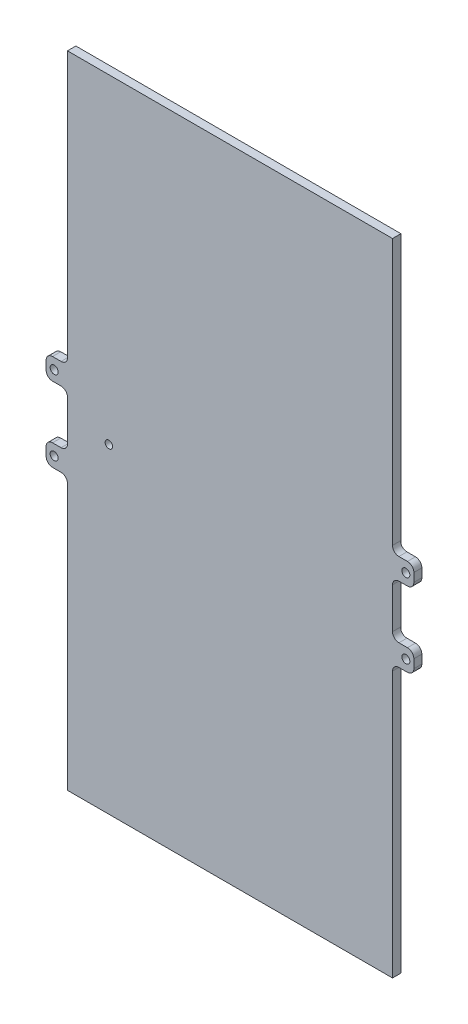
from build123d import *

# Parameters (mm, degrees)
SKETCH1_W               = 120
SKETCH1_H               = 60.9
BOSS_EXTRUDE1_DEPTH     = 1.61
CUT_EXTRUDE1_DEPTH      = 0.5
SKETCH3_W               = 4
SKETCH3_H               = 1.54
BOSS_EXTRUDE2_DEPTH     = 4
SKETCH5_W               = 4
SKETCH5_H               = 1.47
BOSS_EXTRUDE3_DEPTH     = 4
SKETCH7_R               = 0.75
CUT_EXTRUDE3_DEPTH      = 1.07
CUT_EXTRUDE3_DEPTH_BACK = 2.54
FILLET1_R               = 1.2
FILLET2_R               = 1.2
SKETCH8_R               = 0.7
CUT_EXTRUDE4_DEPTH      = 2.61
SKETCH13_W              = 60.9
SKETCH13_H              = 120
CUT_EXTRUDE5_DEPTH      = 0.04
SKETCH14_R              = 0.75
BOSS_EXTRUDE4_DEPTH     = 0.03
SKETCH15_R              = 0.75
CUT_EXTRUDE6_DEPTH      = 0.005


with BuildPart() as part:
    # Sketch1 → Boss-Extrude1 (new body)
    with BuildSketch(Plane(origin=(0, 0, 0), x_dir=(0, 1, 0), z_dir=(0, 0, 1))):
        Rectangle(SKETCH1_W, SKETCH1_H)
    extrude(amount=BOSS_EXTRUDE1_DEPTH)

    # Sketch2 → Cut-Extrude1 (cut)
    with BuildSketch(Plane(origin=(0, 0, 0), x_dir=(1, 0, 0), z_dir=(0, 0, -1))):
        Polygon((28.481704711, 0), (17.415141609, 6.389283186), (17.415141609, -6.389283186), align=None)
    extrude(amount=-CUT_EXTRUDE1_DEPTH, mode=Mode.SUBTRACT)

    # Sketch3 → Boss-Extrude2 (add)
    with BuildSketch(Plane(origin=(-30.45, 0, 0), x_dir=(0, -1, 0), z_dir=(-1, 0, 0))):
        with Locations((-7, 0.805)):
            Rectangle(SKETCH3_W, SKETCH3_H)
        with Locations((7, 0.805)):
            Rectangle(SKETCH3_W, SKETCH3_H)
    extrude(amount=BOSS_EXTRUDE2_DEPTH)

    # Sketch5 → Boss-Extrude3 (add)
    with BuildSketch(Plane.YZ.offset(30.45)):
        with Locations((7, 0.805)):
            Rectangle(SKETCH5_W, SKETCH5_H)
        with Locations((-7, 0.805)):
            Rectangle(SKETCH5_W, SKETCH5_H)
    extrude(amount=BOSS_EXTRUDE3_DEPTH)

    # Sketch7 → Cut-Extrude3 (cut, two sides)
    with BuildSketch(Plane.XY.offset(1.54)) as cut_extrude3_sk:
        with Locations((32.95, 7)):
            Circle(SKETCH7_R)
        with Locations((32.95, -7)):
            Circle(SKETCH7_R)
        with Locations((-32.95, -7)):
            Circle(SKETCH7_R)
        with Locations((-32.95, 7)):
            Circle(SKETCH7_R)
    extrude(amount=CUT_EXTRUDE3_DEPTH, mode=Mode.SUBTRACT)
    extrude(cut_extrude3_sk.sketch, amount=-CUT_EXTRUDE3_DEPTH_BACK, mode=Mode.SUBTRACT)

    # Fillet1
    fillet1_edges = [part.edges().sort_by_distance(p)[0] for p in [
        (-30.45, 5, 0.805),
        (-30.45, 9, 0.805),
        (-30.45, -9, 0.805),
        (-30.45, -5, 0.805),
        (30.45, 9, 0.805),
        (30.45, 5, 0.805),
        (30.45, -5, 0.805),
        (30.45, -9, 0.805),
    ]]
    fillet(fillet1_edges, radius=FILLET1_R)

    # Fillet2
    fillet2_edges = [part.edges().sort_by_distance(p)[0] for p in [
        (-34.45, 9, 0.805),
        (-34.45, 5, 0.805),
        (-34.45, -5, 0.805),
        (-34.45, -9, 0.805),
        (34.45, 5, 0.805),
        (34.45, 9, 0.805),
        (34.45, -9, 0.805),
        (34.45, -5, 0.805),
    ]]
    fillet(fillet2_edges, radius=FILLET2_R)

    # Sketch8 → Cut-Extrude4 (cut, through all)
    with BuildSketch(Plane(origin=(0, 0, 0), x_dir=(1, 0, 0), z_dir=(0, 0, -1))):
        with Locations((-22.7, 0)):
            Circle(SKETCH8_R)
    extrude(amount=-CUT_EXTRUDE4_DEPTH, mode=Mode.SUBTRACT)

    # Sketch13 → Cut-Extrude5 (cut)
    with BuildSketch(Plane.XY.offset(1.61)):
        Rectangle(SKETCH13_W, SKETCH13_H)
    extrude(amount=-CUT_EXTRUDE5_DEPTH, mode=Mode.SUBTRACT)

    # Sketch14 → Boss-Extrude4 (add)
    with BuildSketch(Plane.XY.offset(1.54)):
        with BuildLine():
            Line((31.65, -9), (33.25, -9))
            ThreePointArc((33.25, -9), (34.098528137, -8.648528137), (34.45, -7.8))
            Line((34.45, -7.8), (34.45, -6.2))
            ThreePointArc((34.45, -6.2), (34.098528137, -5.351471863), (33.25, -5))
            Line((33.25, -5), (31.65, -5))
            ThreePointArc((31.65, -5), (30.801471863, -4.648528137), (30.45, -3.8))
            Line((30.45, -3.8), (30.45, -10.2))
            ThreePointArc((30.45, -10.2), (30.801471863, -9.351471863), (31.65, -9))
        make_face()
        with Locations((32.95, -7)):
            Circle(SKETCH14_R, mode=Mode.SUBTRACT)
        with BuildLine():
            Line((34.45, 6.2), (34.45, 7.8))
            ThreePointArc((34.45, 7.8), (34.098528137, 8.648528137), (33.25, 9))
            Line((33.25, 9), (31.65, 9))
            ThreePointArc((31.65, 9), (30.801471863, 9.351471863), (30.45, 10.2))
            Line((30.45, 10.2), (30.45, 3.8))
            ThreePointArc((30.45, 3.8), (30.801471863, 4.648528137), (31.65, 5))
            Line((31.65, 5), (33.25, 5))
            ThreePointArc((33.25, 5), (34.098528137, 5.351471863), (34.45, 6.2))
        make_face()
        with Locations((32.95, 7)):
            Circle(SKETCH14_R, mode=Mode.SUBTRACT)
    extrude(amount=BOSS_EXTRUDE4_DEPTH)

    # Sketch15 → Cut-Extrude6 (cut)
    with BuildSketch(Plane.XY.offset(1.575)):
        with BuildLine():
            Line((-34.45, 7.8), (-34.45, 6.2))
            ThreePointArc((-34.45, 6.2), (-34.098528137, 5.351471863), (-33.25, 5))
            Line((-33.25, 5), (-31.65, 5))
            ThreePointArc((-31.65, 5), (-30.801471863, 4.648528137), (-30.45, 3.8))
            Line((-30.45, 3.8), (-30.45, 10.2))
            ThreePointArc((-30.45, 10.2), (-30.801471863, 9.351471863), (-31.65, 9))
            Line((-31.65, 9), (-33.25, 9))
            ThreePointArc((-33.25, 9), (-34.098528137, 8.648528137), (-34.45, 7.8))
        make_face()
        with Locations((-32.95, 7)):
            Circle(SKETCH15_R, mode=Mode.SUBTRACT)
        with BuildLine():
            Line((-34.45, -6.2), (-34.45, -7.8))
            ThreePointArc((-34.45, -7.8), (-34.098528137, -8.648528137), (-33.25, -9))
            Line((-33.25, -9), (-31.65, -9))
            ThreePointArc((-31.65, -9), (-30.801471863, -9.351471863), (-30.45, -10.2))
            Line((-30.45, -10.2), (-30.45, -3.8))
            ThreePointArc((-30.45, -3.8), (-30.801471863, -4.648528137), (-31.65, -5))
            Line((-31.65, -5), (-33.25, -5))
            ThreePointArc((-33.25, -5), (-34.098528137, -5.351471863), (-34.45, -6.2))
        make_face()
        with Locations((-32.95, -7)):
            Circle(SKETCH15_R, mode=Mode.SUBTRACT)
    extrude(amount=-CUT_EXTRUDE6_DEPTH, mode=Mode.SUBTRACT)


solid = part.part
